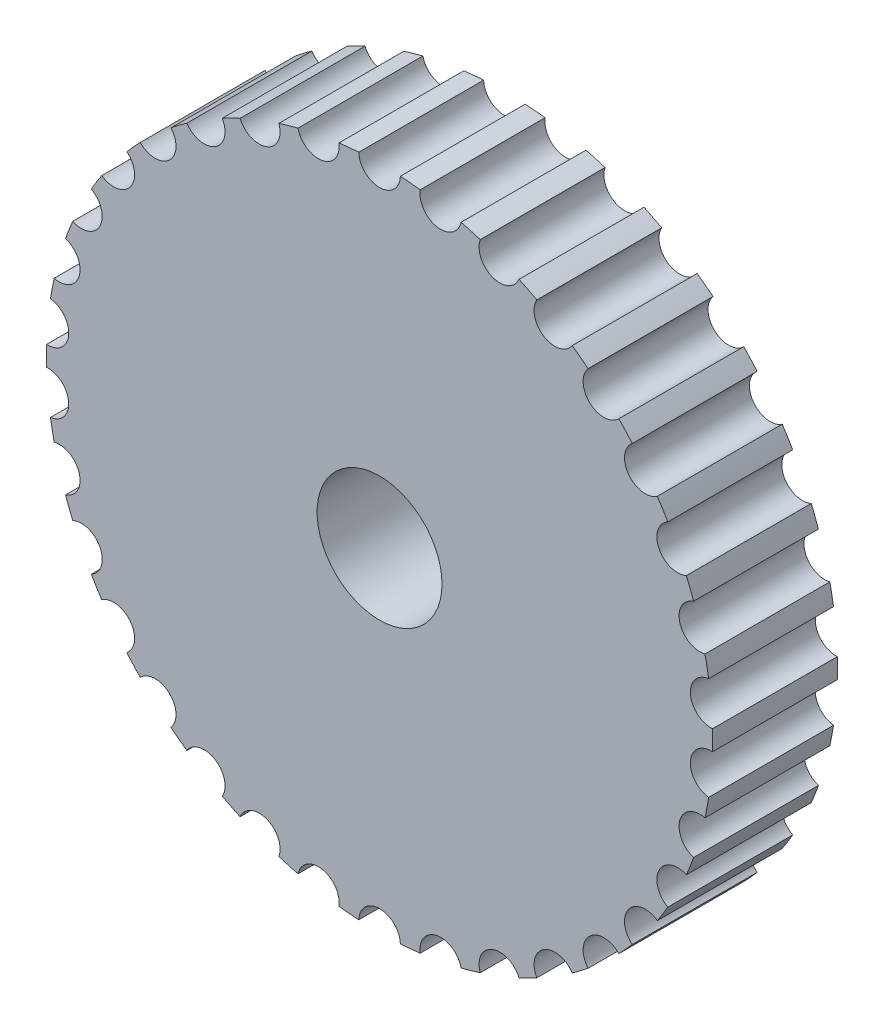
from build123d import *

# Parameters (mm, degrees)
SKETCH1_R           = 1.5
BOSS_EXTRUDE1_DEPTH = 3


with BuildPart() as part:
    # Sketch1 → Boss-Extrude1 (new body)
    with BuildSketch(Plane.XY):
        with BuildLine():
            ThreePointArc((-0.4997558, 7.984375), (-0.738146876, 7.96587341), (-0.975878549, 7.94025573))
            ThreePointArc((-0.975878549, 7.94025573), (-1.378121384, 7.372298248), (-1.958371564, 7.756595956))
            ThreePointArc((-1.958371564, 7.756595956), (-2.189303921, 7.694605145), (-2.418280524, 7.625740574))
            ThreePointArc((-2.418280524, 7.625740574), (-2.709312496, 6.993541721), (-3.350297333, 7.264675339))
            ThreePointArc((-3.350297333, 7.264675339), (-3.565906846, 7.161306331), (-3.778330856, 7.05153997))
            ThreePointArc((-3.778330856, 7.05153997), (-3.948241222, 6.376628518), (-4.628132745, 6.525364917))
            ThreePointArc((-4.628132745, 6.525364917), (-4.821077091, 6.384137818), (-5.009714662, 6.237207629))
            ThreePointArc((-5.009714662, 6.237207629), (-5.052717327, 5.542566879), (-5.748362647, 5.563841018))
            ThreePointArc((-5.748362647, 5.563841018), (-5.912071338, 5.389565149), (-6.070498644, 5.210474662))
            ThreePointArc((-6.070498644, 5.210474662), (-5.985129205, 4.519759773), (-6.672838954, 4.412847187))
            ThreePointArc((-6.672838954, 4.412847187), (-6.801737086, 4.211457303), (-6.924559076, 4.006305231))
            ThreePointArc((-6.924559076, 4.006305231), (-6.713724685, 3.343037668), (-7.370079733, 3.111579138))
            ThreePointArc((-7.370079733, 3.111579138), (-7.459777835, 2.889933329), (-7.542811953, 2.66570588))
            ThreePointArc((-7.542811953, 2.66570588), (-7.213692324, 2.052472426), (-7.816341286, 1.704349993))
            ThreePointArc((-7.816341286, 1.704349993), (-7.863784797, 1.469996143), (-7.904203416, 1.234329112))
            ThreePointArc((-7.904203416, 1.234329112), (-7.468006322, 0.692012696), (-7.996426712, 0.239081253))
            ThreePointArc((-7.996426712, 0.239081253), (-8, 0), (-7.996426712, -0.239081253))
            ThreePointArc((-7.996426712, -0.239081253), (-7.468006322, -0.692012696), (-7.904203416, -1.234329112))
            ThreePointArc((-7.904203416, -1.234329112), (-7.863784797, -1.469996143), (-7.816341286, -1.704349993))
            ThreePointArc((-7.816341286, -1.704349993), (-7.213692324, -2.052472426), (-7.542811953, -2.66570588))
            ThreePointArc((-7.542811953, -2.66570588), (-7.459777835, -2.889933329), (-7.370079733, -3.111579138))
            ThreePointArc((-7.370079733, -3.111579138), (-6.713724685, -3.343037668), (-6.924559076, -4.006305231))
            ThreePointArc((-6.924559076, -4.006305231), (-6.801737086, -4.211457303), (-6.672838954, -4.412847187))
            ThreePointArc((-6.672838954, -4.412847187), (-5.985129205, -4.519759773), (-6.070498644, -5.210474662))
            ThreePointArc((-6.070498644, -5.210474662), (-5.912071338, -5.389565149), (-5.748362647, -5.563841018))
            ThreePointArc((-5.748362647, -5.563841018), (-5.052717327, -5.542566879), (-5.009714662, -6.237207629))
            ThreePointArc((-5.009714662, -6.237207629), (-4.821077091, -6.384137818), (-4.628132745, -6.525364917))
            ThreePointArc((-4.628132745, -6.525364917), (-3.948241222, -6.376628518), (-3.778330856, -7.05153997))
            ThreePointArc((-3.778330856, -7.05153997), (-3.565906846, -7.161306331), (-3.350297333, -7.264675339))
            ThreePointArc((-3.350297333, -7.264675339), (-2.709312496, -6.993541721), (-2.418280524, -7.625740574))
            ThreePointArc((-2.418280524, -7.625740574), (-2.189303921, -7.694605145), (-1.958371564, -7.756595956))
            ThreePointArc((-1.958371564, -7.756595956), (-1.378121384, -7.372298248), (-0.975878549, -7.94025573))
            ThreePointArc((-0.975878549, -7.94025573), (-0.738146876, -7.96587341), (-0.4997558, -7.984375))
            ThreePointArc((-0.4997558, -7.984375), (0, -7.5), (0.4997558, -7.984375))
            ThreePointArc((0.4997558, -7.984375), (0.738146876, -7.96587341), (0.975878549, -7.94025573))
            ThreePointArc((0.975878549, -7.94025573), (1.378121384, -7.372298248), (1.958371564, -7.756595956))
            ThreePointArc((1.958371564, -7.756595956), (2.189303921, -7.694605145), (2.418280524, -7.625740574))
            ThreePointArc((2.418280524, -7.625740574), (2.709312496, -6.993541721), (3.350297333, -7.264675339))
            ThreePointArc((3.350297333, -7.264675339), (3.565906846, -7.161306331), (3.778330856, -7.05153997))
            ThreePointArc((3.778330856, -7.05153997), (3.948241222, -6.376628518), (4.628132745, -6.525364917))
            ThreePointArc((4.628132745, -6.525364917), (4.821077091, -6.384137818), (5.009714662, -6.237207629))
            ThreePointArc((5.009714662, -6.237207629), (5.052717327, -5.542566879), (5.748362647, -5.563841018))
            ThreePointArc((5.748362647, -5.563841018), (5.912071338, -5.389565149), (6.070498644, -5.210474662))
            ThreePointArc((6.070498644, -5.210474662), (5.985129205, -4.519759773), (6.672838954, -4.412847187))
            ThreePointArc((6.672838954, -4.412847187), (6.801737086, -4.211457303), (6.924559076, -4.006305231))
            ThreePointArc((6.924559076, -4.006305231), (6.713724685, -3.343037668), (7.370079733, -3.111579138))
            ThreePointArc((7.370079733, -3.111579138), (7.459777835, -2.889933329), (7.542811953, -2.66570588))
            ThreePointArc((7.542811953, -2.66570588), (7.213692324, -2.052472426), (7.816341286, -1.704349993))
            ThreePointArc((7.816341286, -1.704349993), (7.863784797, -1.469996143), (7.904203416, -1.234329112))
            ThreePointArc((7.904203416, -1.234329112), (7.468006322, -0.692012696), (7.996426712, -0.239081253))
            ThreePointArc((7.996426712, -0.239081253), (8, 0), (7.996426712, 0.239081253))
            ThreePointArc((7.996426712, 0.239081253), (7.468006322, 0.692012696), (7.904203416, 1.234329112))
            ThreePointArc((7.904203416, 1.234329112), (7.863784797, 1.469996143), (7.816341286, 1.704349993))
            ThreePointArc((7.816341286, 1.704349993), (7.213692324, 2.052472426), (7.542811953, 2.66570588))
            ThreePointArc((7.542811953, 2.66570588), (7.459777835, 2.889933329), (7.370079733, 3.111579138))
            ThreePointArc((7.370079733, 3.111579138), (6.713724685, 3.343037668), (6.924559076, 4.006305231))
            ThreePointArc((6.924559076, 4.006305231), (6.801737086, 4.211457303), (6.672838954, 4.412847187))
            ThreePointArc((6.672838954, 4.412847187), (5.985129205, 4.519759773), (6.070498644, 5.210474662))
            ThreePointArc((6.070498644, 5.210474662), (5.912071338, 5.389565149), (5.748362647, 5.563841018))
            ThreePointArc((5.748362647, 5.563841018), (5.052717327, 5.542566879), (5.009714662, 6.237207629))
            ThreePointArc((5.009714662, 6.237207629), (4.821077091, 6.384137818), (4.628132745, 6.525364917))
            ThreePointArc((4.628132745, 6.525364917), (3.948241222, 6.376628518), (3.778330856, 7.05153997))
            ThreePointArc((3.778330856, 7.05153997), (3.565906846, 7.161306331), (3.350297333, 7.264675339))
            ThreePointArc((3.350297333, 7.264675339), (2.709312496, 6.993541721), (2.418280524, 7.625740574))
            ThreePointArc((2.418280524, 7.625740574), (2.189303921, 7.694605145), (1.958371564, 7.756595956))
            ThreePointArc((1.958371564, 7.756595956), (1.378121384, 7.372298248), (0.975878549, 7.94025573))
            ThreePointArc((0.975878549, 7.94025573), (0.738146876, 7.96587341), (0.4997558, 7.984375))
            ThreePointArc((0.4997558, 7.984375), (0, 7.5), (-0.4997558, 7.984375))
        make_face()
        Circle(SKETCH1_R, mode=Mode.SUBTRACT)
    extrude(amount=BOSS_EXTRUDE1_DEPTH)


solid = part.part
